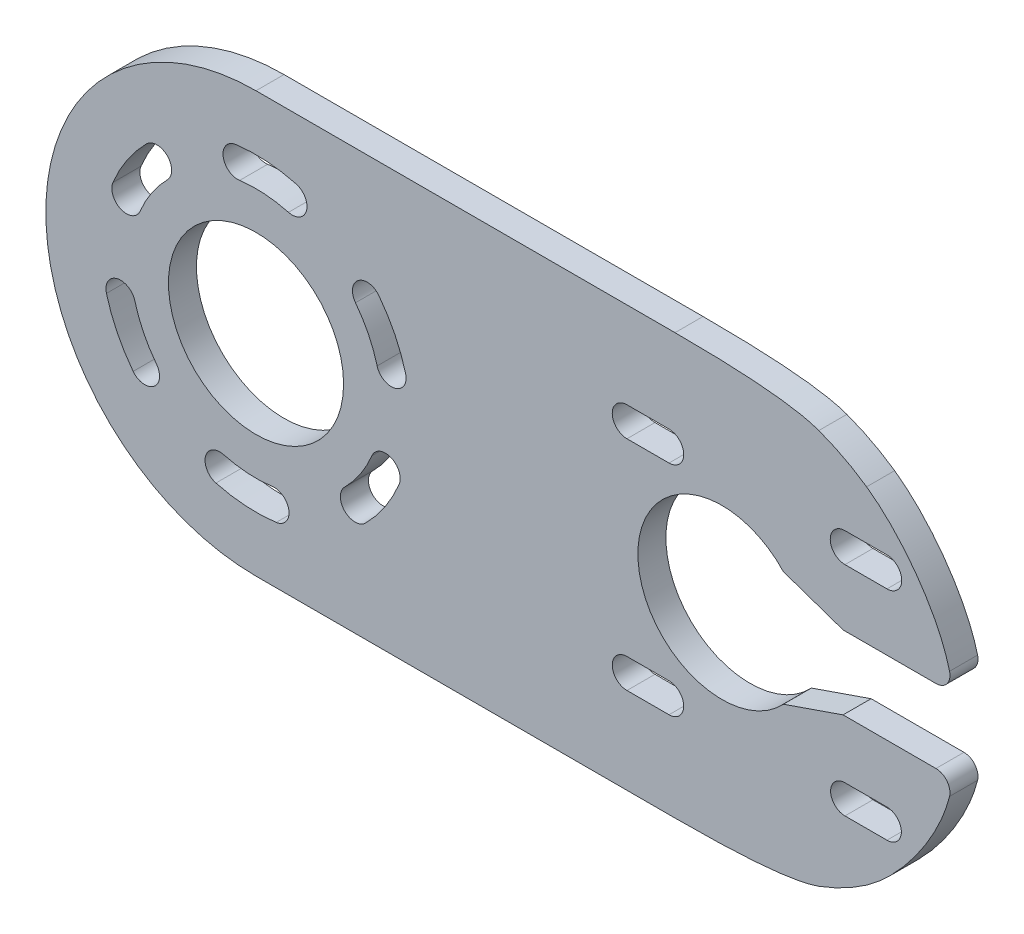
from build123d import *

# Parameters (mm, degrees)
SKIZZE2_R                       = 12.5
AUFSATZ_LINEAR_AUSTRAGEN2_DEPTH = 4


with BuildPart() as part:
    # Skizze2 → Aufsatz-Linear austragen2 (new body)
    with BuildSketch(Plane.XY):
        with BuildLine():
            Line((-36.002800277, 29.622112019), (23.801047301, 29.622112019))
            add(Edge.make_bspline(
                [(23.801047301, 29.622112019), (39.324007896, 29.622112019), (44.325198534, 27.788269736)],
                knots=[0, 0, 0, 1, 1, 1], degree=2))
            ThreePointArc((44.325198534, 27.788269736), (47.84965812, 26.232437014), (51.145668645, 24.237757727))
            add(Edge.make_bspline(
                [(51.145668645, 24.237757727), (55.926029521, 20.907523335), (61.370340825, 13.799078949), (62.982460357, 7.357685339)],
                knots=[0, 0, 0, 0, 1, 1, 1, 1], degree=3))
            ThreePointArc((62.982460357, 7.357685339), (62.618871056, 5.641491574), (61.042300943, 4.872112019))
            Line((61.042300943, 4.872112019), (47.785287356, 4.872112019))
            Line((47.785287356, 4.872112019), (39.265024534, 7.815111963))
            ThreePointArc((39.265024534, 7.815111963), (18.497199723, -0.377887981), (39.265024534, -8.570887926))
            Line((39.265024534, -8.570887926), (47.785287356, -5.627887981))
            Line((47.785287356, -5.627887981), (61.042300943, -5.627887981))
            ThreePointArc((61.042300943, -5.627887981), (62.618871056, -6.397267536), (62.982460357, -8.113461302))
            add(Edge.make_bspline(
                [(51.145668645, -24.99353369), (55.926029521, -21.663299298), (61.370340825, -14.554854912), (62.982460357, -8.113461302)],
                knots=[0, 0, 0, 0, 1, 1, 1, 1], degree=3))
            ThreePointArc((51.145668645, -24.99353369), (47.84965812, -26.988212977), (44.325198534, -28.544045699))
            add(Edge.make_bspline(
                [(23.801047301, -30.377887981), (39.324007896, -30.377887981), (44.325198534, -28.544045699)],
                knots=[0, 0, 0, 1, 1, 1], degree=2))
            Line((23.801047301, -30.377887981), (-36.002800277, -30.377887981))
            ThreePointArc((-36.002800277, -30.377887981), (-66.002800277, -0.377887981), (-36.002800277, 29.622112019))
        make_face()
        with Locations((-36.002800277, -0.377887981)):
            Circle(SKIZZE2_R, mode=Mode.SUBTRACT)
        with BuildLine():
            Line((22.940850537, 17.278461205), (16.940850537, 17.278461205))
            ThreePointArc((16.940850537, 17.278461205), (14.840850537, 15.178461205), (16.940850537, 13.078461205))
            Line((16.940850537, 13.078461205), (22.940850537, 13.078461205))
            ThreePointArc((22.940850537, 13.078461205), (25.040850537, 15.178461205), (22.940850537, 17.278461205))
        make_face(mode=Mode.SUBTRACT)
        with BuildLine():
            Line((48.05354891, 13.078461205), (54.05354891, 13.078461205))
            ThreePointArc((54.05354891, 13.078461205), (56.15354891, 15.178461205), (54.05354891, 17.278461205))
            Line((54.05354891, 17.278461205), (48.05354891, 17.278461205))
            ThreePointArc((48.05354891, 17.278461205), (45.95354891, 15.178461205), (48.05354891, 13.078461205))
        make_face(mode=Mode.SUBTRACT)
        with BuildLine():
            Line((48.05354891, -17.984237167), (54.05354891, -17.984237167))
            ThreePointArc((54.05354891, -17.984237167), (56.10354891, -15.934237167), (54.05354891, -13.884237167))
            Line((54.05354891, -13.884237167), (48.05354891, -13.884237167))
            ThreePointArc((48.05354891, -13.884237167), (46.00354891, -15.934237167), (48.05354891, -17.984237167))
        make_face(mode=Mode.SUBTRACT)
        with BuildLine():
            Line((22.940850537, -13.834237167), (16.940850537, -13.834237167))
            ThreePointArc((16.940850537, -13.834237167), (14.840850537, -15.934237167), (16.940850537, -18.034237167))
            Line((16.940850537, -18.034237167), (22.940850537, -18.034237167))
            ThreePointArc((22.940850537, -18.034237167), (25.040850537, -15.934237167), (22.940850537, -13.834237167))
        make_face(mode=Mode.SUBTRACT)
        with BuildLine():
            ThreePointArc((-23.345588893, -13.035099365), (-21.119494216, -10.322595152), (-19.465356645, -7.227921421))
            ThreePointArc((-19.465356645, -7.227921421), (-16.721574418, -6.09140961), (-15.585062608, -8.835191837))
            ThreePointArc((-15.585062608, -8.835191837), (-17.627321845, -12.655990131), (-20.375740412, -16.004947846))
            ThreePointArc((-20.375740412, -16.004947846), (-23.345588893, -16.004947846), (-23.345588893, -13.035099365))
        make_face(mode=Mode.SUBTRACT)
        with BuildLine():
            ThreePointArc((-40.635661184, -17.667960272), (-37.17351629, -18.239562707), (-33.666381436, -18.124751))
            ThreePointArc((-33.666381436, -18.124751), (-31.310242223, -19.932680205), (-33.118171429, -22.288819418))
            ThreePointArc((-33.118171429, -22.288819418), (-37.448209433, -22.430570185), (-41.722701173, -21.724848742))
            ThreePointArc((-41.722701173, -21.724848742), (-43.207625414, -19.152884512), (-40.635661184, -17.667960272))
        make_face(mode=Mode.SUBTRACT)
        with BuildLine():
            ThreePointArc((-53.292872567, -5.010748889), (-52.05682235, -8.294855536), (-50.203825068, -11.274717561))
            ThreePointArc((-50.203825068, -11.274717561), (-50.591468081, -14.219158576), (-53.535909097, -13.831515562))
            ThreePointArc((-53.535909097, -13.831515562), (-55.823687864, -10.152468035), (-57.349761038, -6.097788878))
            ThreePointArc((-57.349761038, -6.097788878), (-55.864836797, -3.525824648), (-53.292872567, -5.010748889))
        make_face(mode=Mode.SUBTRACT)
        with BuildLine():
            ThreePointArc((-48.66001166, 12.279323402), (-50.886106337, 9.56681919), (-52.540243909, 6.472145458))
            ThreePointArc((-52.540243909, 6.472145458), (-55.284026135, 5.335633648), (-56.420537945, 8.079415874))
            ThreePointArc((-56.420537945, 8.079415874), (-54.378278708, 11.900214168), (-51.629860141, 15.249171883))
            ThreePointArc((-51.629860141, 15.249171883), (-48.66001166, 15.249171883), (-48.66001166, 12.279323402))
        make_face(mode=Mode.SUBTRACT)
        with BuildLine():
            ThreePointArc((-31.369939369, 16.912184309), (-34.832084263, 17.483786745), (-38.339219117, 17.368975037))
            ThreePointArc((-38.339219117, 17.368975037), (-40.69535833, 19.176904242), (-38.887429125, 21.533043455))
            ThreePointArc((-38.887429125, 21.533043455), (-34.557391121, 21.674794222), (-30.28289938, 20.96907278))
            ThreePointArc((-30.28289938, 20.96907278), (-28.797975139, 18.39710855), (-31.369939369, 16.912184309))
        make_face(mode=Mode.SUBTRACT)
        with BuildLine():
            ThreePointArc((-18.712727986, 4.254972926), (-16.140763756, 2.770048686), (-14.655839516, 5.342012915))
            ThreePointArc((-14.655839516, 5.342012915), (-16.181912689, 9.396692073), (-18.469691456, 13.0757396))
            ThreePointArc((-18.469691456, 13.0757396), (-21.414132472, 13.463382613), (-21.801775485, 10.518941598))
            ThreePointArc((-21.801775485, 10.518941598), (-19.948778203, 7.539079574), (-18.712727986, 4.254972926))
        make_face(mode=Mode.SUBTRACT)
    extrude(amount=AUFSATZ_LINEAR_AUSTRAGEN2_DEPTH)


solid = part.part
